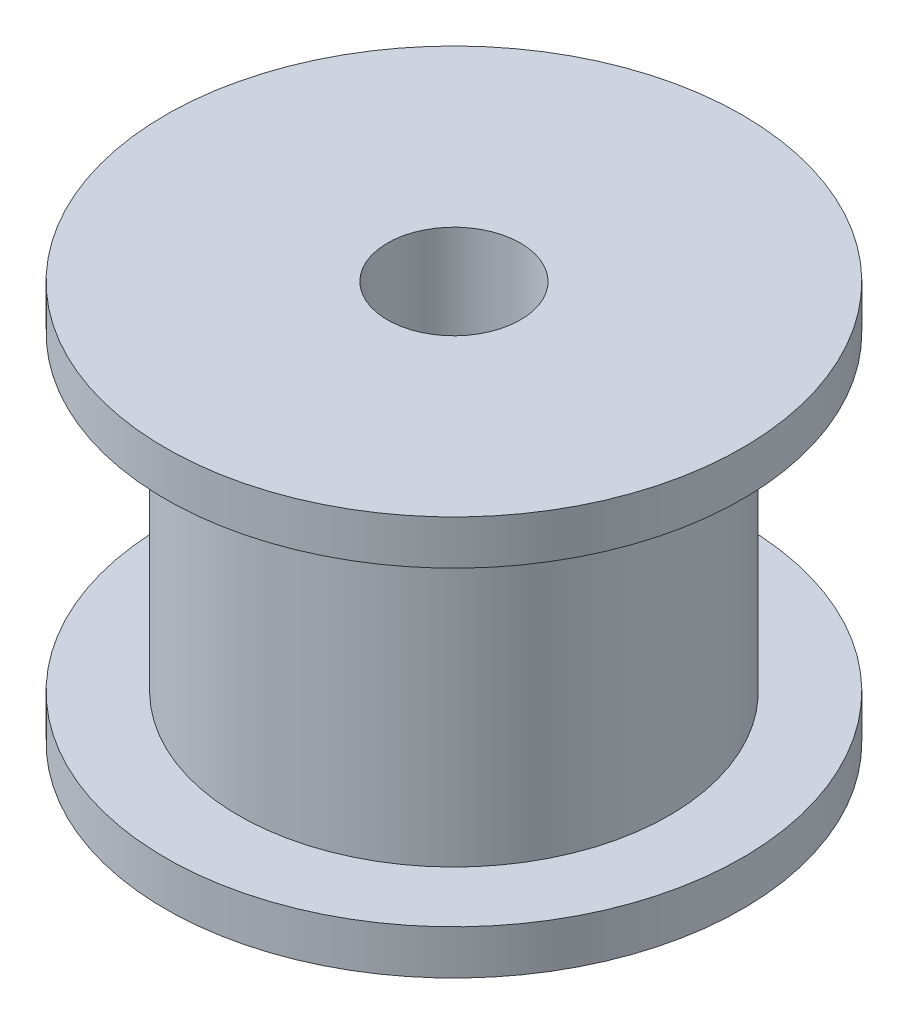
from build123d import *


with BuildPart() as part:
    # Sketch2 → Revolve1 (revolve)
    with BuildSketch(Plane(origin=(0, 0, 0), x_dir=(0, 0, -1), z_dir=(1, 0, 0))):
        Polygon((4.85, 3.983820311), (4.85, -3.016179689), (6.5, -3.016179689), (6.5, -4.016179689), (1.5, -4.016179689), (1.5, 4.983820311), (6.5, 4.983820311), (6.5, 3.983820311), align=None)
    revolve(axis=Axis((0, 0, 0), (0, 1, 0)))


solid = part.part
